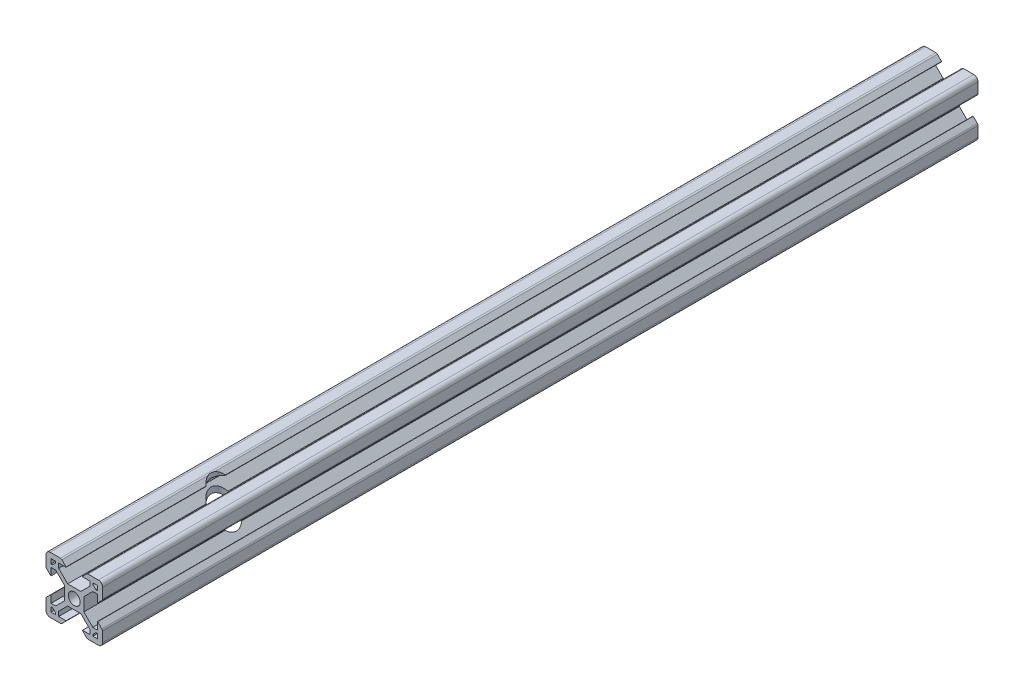
from build123d import *

# Parameters (mm, degrees)
SKETCH6_R               = 2.1
BOSS_EXTRUDE1_DEPTH     = 310
SKETCH7_R               = 4.5
CUT_EXTRUDE1_DEPTH      = 11
CUT_EXTRUDE1_DEPTH_BACK = 11


with BuildPart() as part:
    # Sketch6 → Boss-Extrude1 (new body)
    with BuildSketch(Plane.XY):
        with BuildLine():
            Line((-3.4, -2.339339828), (-3.4, 2.339339828))
            Line((-3.4, 2.339339828), (-6.560660172, 5.5))
            Line((-6.560660172, 5.5), (-8.2, 5.5))
            Line((-8.2, 5.5), (-8.2, 2.89))
            Line((-8.2, 2.89), (-8.31, 2.89))
            Line((-8.31, 2.89), (-9.768614357, 4.348614357))
            ThreePointArc((-9.768614357, 4.348614357), (-9.939864831, 4.604908803), (-10, 4.907228714))
            Line((-10, 4.907228714), (-10, 8.5))
            ThreePointArc((-10, 8.5), (-9.560660172, 9.560660172), (-8.5, 10))
            Line((-8.5, 10), (-4.907228714, 10))
            ThreePointArc((-4.907228714, 10), (-4.604908803, 9.939864831), (-4.348614357, 9.768614357))
            Line((-4.348614357, 9.768614357), (-2.89, 8.31))
            Line((-2.89, 8.31), (-2.89, 8.2))
            Line((-2.89, 8.2), (-5.5, 8.2))
            Line((-5.5, 8.2), (-5.5, 6.560660172))
            Line((-5.5, 6.560660172), (-2.339339828, 3.4))
            Line((-2.339339828, 3.4), (2.339339828, 3.4))
            Line((2.339339828, 3.4), (5.5, 6.560660172))
            Line((5.5, 6.560660172), (5.5, 8.2))
            Line((5.5, 8.2), (2.89, 8.2))
            Line((2.89, 8.2), (2.89, 8.31))
            Line((2.89, 8.31), (4.348614357, 9.768614357))
            ThreePointArc((4.348614357, 9.768614357), (4.604908803, 9.939864831), (4.907228714, 10))
            Line((4.907228714, 10), (8.5, 10))
            ThreePointArc((8.5, 10), (9.560660172, 9.560660172), (10, 8.5))
            Line((10, 8.5), (10, 4.907228714))
            ThreePointArc((10, 4.907228714), (9.939864831, 4.604908803), (9.768614357, 4.348614357))
            Line((9.768614357, 4.348614357), (8.31, 2.89))
            Line((8.31, 2.89), (8.2, 2.89))
            Line((8.2, 2.89), (8.2, 5.5))
            Line((8.2, 5.5), (6.560660172, 5.5))
            Line((6.560660172, 5.5), (3.4, 2.339339828))
            Line((3.4, 2.339339828), (3.4, -2.339339828))
            Line((3.4, -2.339339828), (6.560660172, -5.5))
            Line((6.560660172, -5.5), (8.2, -5.5))
            Line((8.2, -5.5), (8.2, -2.89))
            Line((8.2, -2.89), (8.31, -2.89))
            Line((8.31, -2.89), (9.768614357, -4.348614357))
            ThreePointArc((9.768614357, -4.348614357), (9.939864831, -4.604908803), (10, -4.907228714))
            Line((10, -4.907228714), (10, -8.5))
            ThreePointArc((10, -8.5), (9.560660172, -9.560660172), (8.5, -10))
            Line((8.5, -10), (4.907228714, -10))
            ThreePointArc((4.907228714, -10), (4.604908803, -9.939864831), (4.348614357, -9.768614357))
            Line((4.348614357, -9.768614357), (2.89, -8.31))
            Line((2.89, -8.31), (2.89, -8.2))
            Line((2.89, -8.2), (5.5, -8.2))
            Line((5.5, -8.2), (5.5, -6.560660172))
            Line((5.5, -6.560660172), (2.339339828, -3.4))
            Line((2.339339828, -3.4), (-2.339339828, -3.4))
            Line((-2.339339828, -3.4), (-5.5, -6.560660172))
            Line((-5.5, -6.560660172), (-5.5, -8.2))
            Line((-5.5, -8.2), (-2.89, -8.2))
            Line((-2.89, -8.2), (-2.89, -8.31))
            Line((-2.89, -8.31), (-4.348614357, -9.768614357))
            ThreePointArc((-4.348614357, -9.768614357), (-4.604908803, -9.939864831), (-4.907228714, -10))
            Line((-4.907228714, -10), (-8.5, -10))
            ThreePointArc((-8.5, -10), (-9.560660172, -9.560660172), (-10, -8.5))
            Line((-10, -8.5), (-10, -4.907228714))
            ThreePointArc((-10, -4.907228714), (-9.939864831, -4.604908803), (-9.768614357, -4.348614357))
            Line((-9.768614357, -4.348614357), (-8.31, -2.89))
            Line((-8.31, -2.89), (-8.2, -2.89))
            Line((-8.2, -2.89), (-8.2, -5.5))
            Line((-8.2, -5.5), (-6.560660172, -5.5))
            Line((-6.560660172, -5.5), (-3.4, -2.339339828))
        make_face()
        Circle(SKETCH6_R, mode=Mode.SUBTRACT)
        Polygon((-7.66, 6.57), (-6.57, 7.66), (-6.57, 8.2), (-8.2, 8.2), (-8.2, 6.57), align=None, mode=Mode.SUBTRACT)
        Polygon((8.2, 6.57), (7.66, 6.57), (6.57, 7.66), (6.57, 8.2), (8.2, 8.2), align=None, mode=Mode.SUBTRACT)
        Polygon((7.66, -6.57), (6.57, -7.66), (6.57, -8.2), (8.2, -8.2), (8.2, -6.57), align=None, mode=Mode.SUBTRACT)
        Polygon((-8.2, -6.57), (-7.66, -6.57), (-6.57, -7.66), (-6.57, -8.2), (-8.2, -8.2), align=None, mode=Mode.SUBTRACT)
    extrude(amount=-BOSS_EXTRUDE1_DEPTH)

    # Sketch7 → Cut-Extrude1 (cut, two sides)
    with BuildSketch(Plane(origin=(0, 0, 0), x_dir=(1, 0, 0), z_dir=(0, 1, 0))) as cut_extrude1_sk:
        with Locations((0, 52.93)):
            Circle(SKETCH7_R)
    extrude(amount=CUT_EXTRUDE1_DEPTH, mode=Mode.SUBTRACT)
    extrude(cut_extrude1_sk.sketch, amount=-CUT_EXTRUDE1_DEPTH_BACK, mode=Mode.SUBTRACT)


solid = part.part
